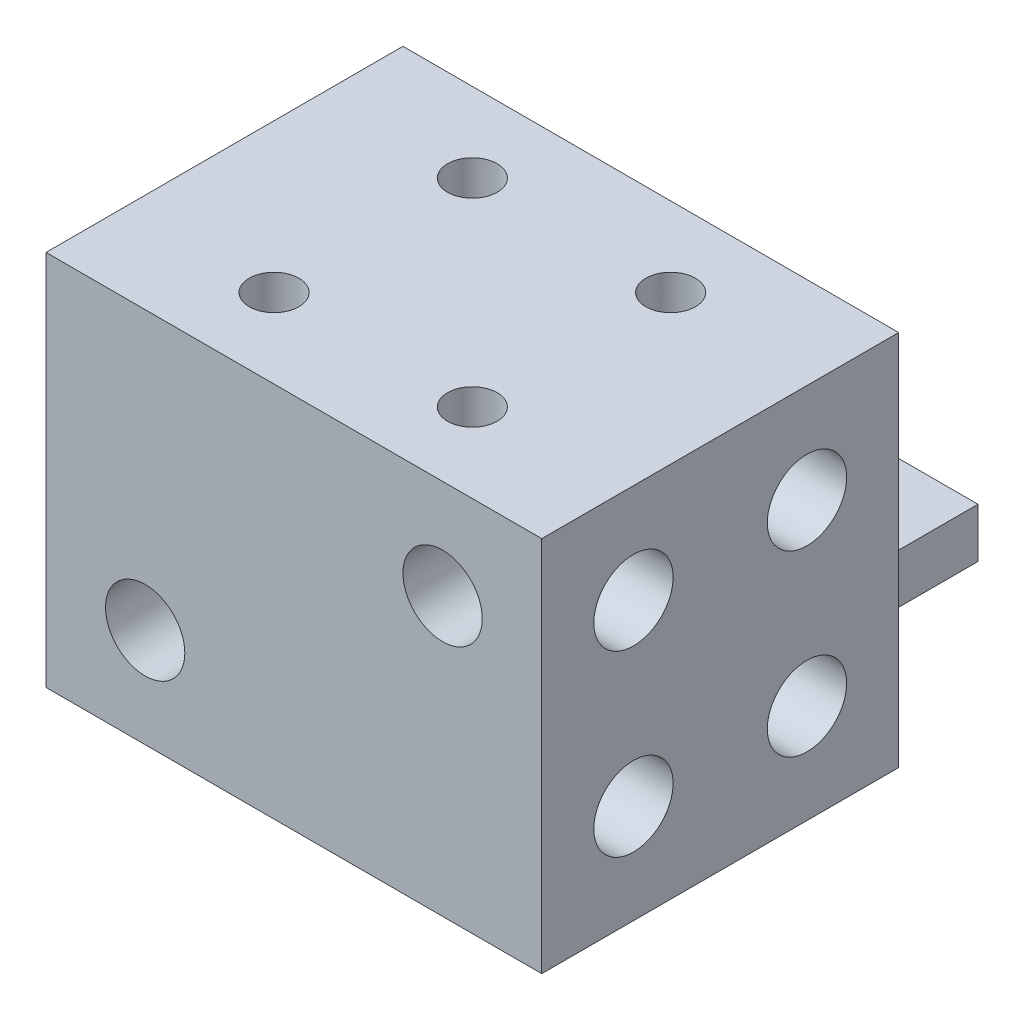
from build123d import *

# Parameters (mm, degrees)
SKETCH2_W           = 50
SKETCH2_H           = 36
BOSS_EXTRUDE1_DEPTH = 19
SKETCH3_W           = 22
SKETCH3_H           = 44
BOSS_EXTRUDE3_DEPTH = 5
SKETCH4_R           = 4
CUT_EXTRUDE1_DEPTH  = 50
SKETCH5_R           = 4
CUT_EXTRUDE2_DEPTH  = 15
SKETCH6_R           = 4
CUT_EXTRUDE3_DEPTH  = 16
SKETCH24_R          = 7.5
CUT_EXTRUDE4_DEPTH  = 5
SKETCH25_R          = 1.5
CUT_EXTRUDE5_DEPTH  = 3
SKETCH26_R          = 2.5
CUT_EXTRUDE6_DEPTH  = 36


with BuildPart() as part:
    # Sketch2 → Boss-Extrude1 (new body, symmetric)
    with BuildSketch(Plane(origin=(0, 0, 0), x_dir=(1, 0, 0), z_dir=(0, 1, 0))):
        Rectangle(SKETCH2_W, SKETCH2_H)
    extrude(amount=BOSS_EXTRUDE1_DEPTH, both=True)

    # Sketch3 → Boss-Extrude3 (add)
    with BuildSketch(Plane.XZ.offset(19)):
        with Locations((0, -18)):
            Rectangle(SKETCH3_W, SKETCH3_H)
    extrude(amount=-BOSS_EXTRUDE3_DEPTH)

    # Sketch4 → Cut-Extrude1 (cut)
    with BuildSketch(Plane.ZY.offset(25)):
        with Locations((-8.75, -9)):
            Circle(SKETCH4_R)
        with Locations((8.75, -9)):
            Circle(SKETCH4_R)
        with Locations((8.75, 9)):
            Circle(SKETCH4_R)
        with Locations((-8.75, 9)):
            Circle(SKETCH4_R)
    extrude(amount=-CUT_EXTRUDE1_DEPTH, mode=Mode.SUBTRACT)

    # Sketch5 → Cut-Extrude2 (cut)
    with BuildSketch(Plane(origin=(0, 0, -18), x_dir=(-1, 0, 0), z_dir=(0, 0, -1))):
        with Locations((-15, -9)):
            Circle(SKETCH5_R)
        with Locations((15, 9)):
            Circle(SKETCH5_R)
    extrude(amount=-CUT_EXTRUDE2_DEPTH, mode=Mode.SUBTRACT)

    # Sketch6 → Cut-Extrude3 (cut)
    with BuildSketch(Plane.XY.offset(18)):
        with Locations((-15, -9)):
            Circle(SKETCH6_R)
        with Locations((15, 9)):
            Circle(SKETCH6_R)
    extrude(amount=-CUT_EXTRUDE3_DEPTH, mode=Mode.SUBTRACT)

    # Sketch24 → Cut-Extrude4 (cut)
    with BuildSketch(Plane(origin=(0, -14, 0), x_dir=(1, 0, 0), z_dir=(0, 1, 0))):
        with Locations((0, 29)):
            Circle(SKETCH24_R)
    extrude(amount=-CUT_EXTRUDE4_DEPTH, mode=Mode.SUBTRACT)

    # Sketch25 → Cut-Extrude5 (cut)
    with BuildSketch(Plane(origin=(0, -19, 0), x_dir=(1, 0, 0), z_dir=(0, 1, 0))):
        with Locations((-10, 10)):
            Circle(SKETCH25_R)
        with Locations((10, 10)):
            Circle(SKETCH25_R)
        with Locations((10, -10)):
            Circle(SKETCH25_R)
        with Locations((-10, -10)):
            Circle(SKETCH25_R)
    extrude(amount=CUT_EXTRUDE5_DEPTH, mode=Mode.SUBTRACT)

    # Sketch26 → Cut-Extrude6 (cut, through all)
    with BuildSketch(Plane(origin=(0, -16, 0), x_dir=(-1, 0, 0), z_dir=(0, -1, 0))):
        with Locations((-10, 10)):
            Circle(SKETCH26_R)
        with Locations((10, 10)):
            Circle(SKETCH26_R)
        with Locations((10, -10)):
            Circle(SKETCH26_R)
        with Locations((-10, -10)):
            Circle(SKETCH26_R)
    extrude(amount=-CUT_EXTRUDE6_DEPTH, mode=Mode.SUBTRACT)


solid = part.part
